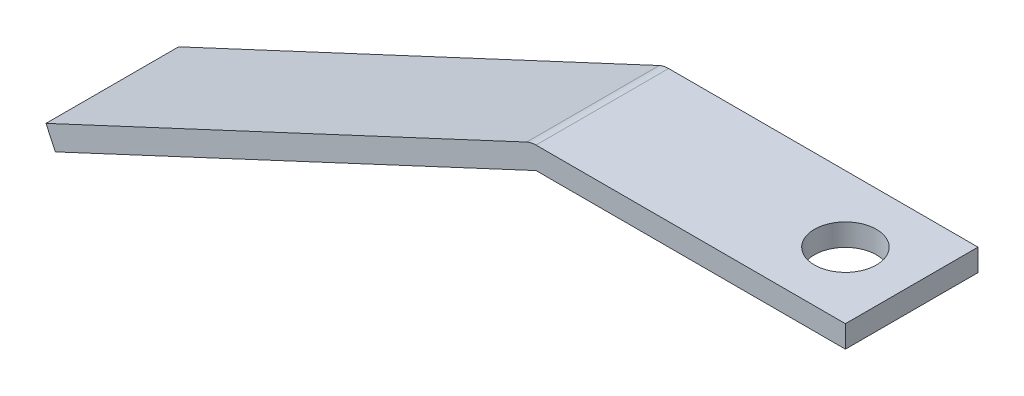
from build123d import *

# Parameters (mm, degrees)
BOSS_EXTRUDE1_DEPTH = 38.1
SKETCH2_R           = 17.78
CUT_EXTRUDE1_DEPTH  = 142.514046179


with BuildPart() as part:
    # Sketch1 → Boss-Extrude1 (new body, symmetric)
    with BuildSketch(Plane.XY):
        with BuildLine():
            Line((0, 0), (-177.8, 0))
            Line((-177.8, 0), (-454.042613489, -128.814046179))
            Line((-454.042613489, -128.814046179), (-459.409865413, -117.303937283))
            Line((-459.409865413, -117.303937283), (-183.167251924, 11.510108895))
            ThreePointArc((-183.167251924, 11.510108895), (-180.548783097, 12.39895929), (-177.8, 12.7))
            Line((-177.8, 12.7), (0, 12.7))
            Line((0, 12.7), (0, 0))
        make_face()
    extrude(amount=BOSS_EXTRUDE1_DEPTH, both=True)

    # Sketch2 → Cut-Extrude1 (cut, through all)
    with BuildSketch(Plane(origin=(0, 12.7, 0), x_dir=(1, 0, 0), z_dir=(0, 1, 0))):
        with Locations((-38.1, 0)):
            Circle(SKETCH2_R)
    extrude(amount=-CUT_EXTRUDE1_DEPTH, mode=Mode.SUBTRACT)


solid = part.part
